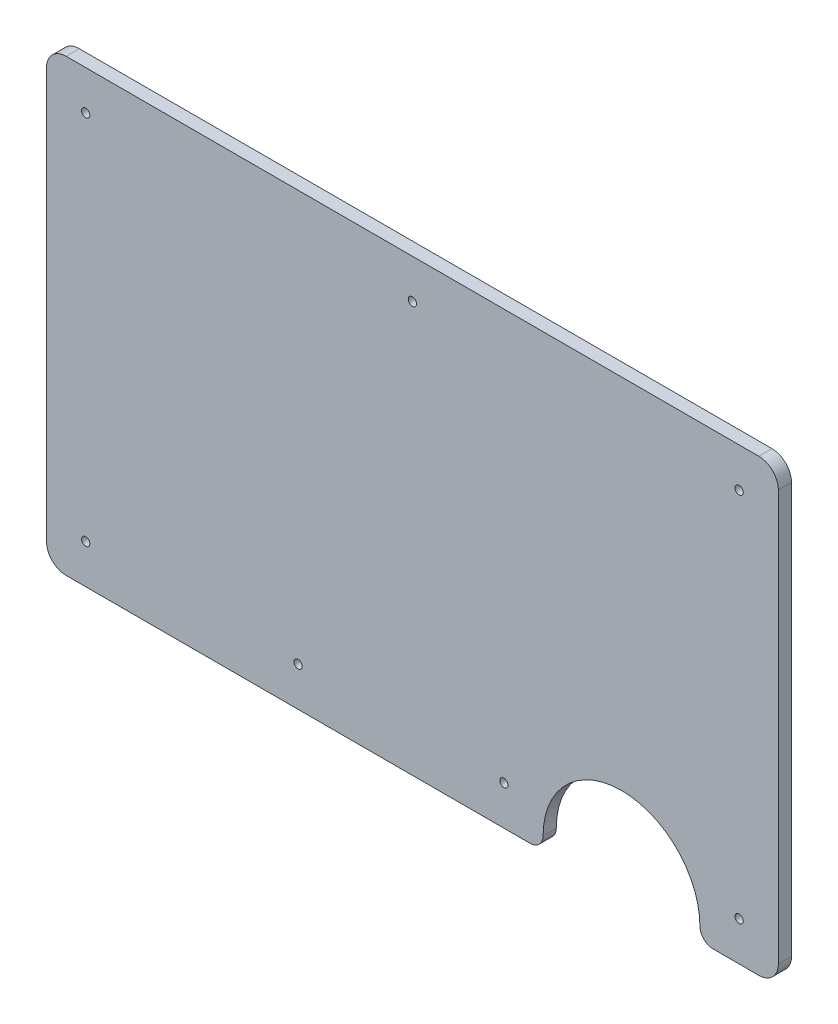
from build123d import *

# Parameters (mm, degrees)
SKETCH1_R           = 0.5
BOSS_EXTRUDE1_DEPTH = 1.6


with BuildPart() as part:
    # Sketch1 → Boss-Extrude1 (new body)
    with BuildSketch(Plane.XY.offset(1.6)):
        with BuildLine():
            Line((0, 53.320743496), (0, 3.473243496))
            ThreePointArc((0, 3.473243496), (0.697451977, 1.789445473), (2.38125, 1.091993496))
            Line((2.38125, 1.091993496), (58.7375, 1.091993496))
            ThreePointArc((58.7375, 1.091993496), (59.860032015, 1.556961481), (60.325, 2.679493496))
            ThreePointArc((60.325, 2.679493496), (69.85, 12.204493496), (79.375, 2.679493496))
            ThreePointArc((79.375, 2.679493496), (79.839967985, 1.556961481), (80.9625, 1.091993496))
            Line((80.9625, 1.091993496), (86.51875, 1.091993496))
            ThreePointArc((86.51875, 1.091993496), (88.202548023, 1.789445473), (88.9, 3.473243496))
            Line((88.9, 3.473243496), (88.9, 53.320743496))
            ThreePointArc((88.9, 53.320743496), (88.202548023, 55.004541519), (86.51875, 55.701993496))
            Line((86.51875, 55.701993496), (2.38125, 55.701993496))
            ThreePointArc((2.38125, 55.701993496), (0.697451977, 55.004541519), (0, 53.320743496))
        make_face()
        with Locations((4.7625, 50.939493496)):
            Circle(SKETCH1_R, mode=Mode.SUBTRACT)
        with Locations((4.7625, 5.854493496)):
            Circle(SKETCH1_R, mode=Mode.SUBTRACT)
        with Locations((84.1375, 5.854493496)):
            Circle(SKETCH1_R, mode=Mode.SUBTRACT)
        with Locations((84.1375, 50.939493496)):
            Circle(SKETCH1_R, mode=Mode.SUBTRACT)
        with Locations((30.559375, 5.854493496)):
            Circle(SKETCH1_R, mode=Mode.SUBTRACT)
        with Locations((55.5625, 5.854493496)):
            Circle(SKETCH1_R, mode=Mode.SUBTRACT)
        with Locations((44.45, 50.939493496)):
            Circle(SKETCH1_R, mode=Mode.SUBTRACT)
    extrude(amount=-BOSS_EXTRUDE1_DEPTH)


solid = part.part
